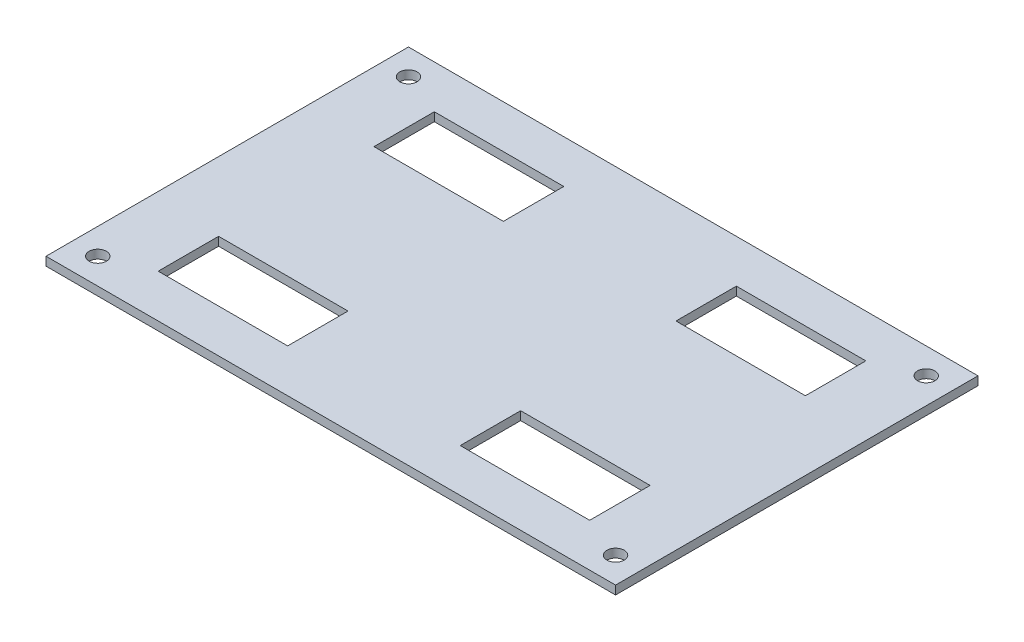
from build123d import *

# Parameters (mm, degrees)
SKETCH1_W           = 66
SKETCH1_H           = 42
SKETCH1_R           = 1
SKETCH1_W_2         = 15
SKETCH1_H_2         = 7
BOSS_EXTRUDE1_DEPTH = 1


with BuildPart() as part:
    # Sketch1 → Boss-Extrude1 (new body)
    with BuildSketch(Plane(origin=(0, 0, 0), x_dir=(1, 0, 0), z_dir=(0, 1, 0))):
        Rectangle(SKETCH1_W, SKETCH1_H)
        with Locations((-30, -18)):
            Circle(SKETCH1_R, mode=Mode.SUBTRACT)
        with Locations((30, -18)):
            Circle(SKETCH1_R, mode=Mode.SUBTRACT)
        with Locations((30, 18)):
            Circle(SKETCH1_R, mode=Mode.SUBTRACT)
        with Locations((-30, 18)):
            Circle(SKETCH1_R, mode=Mode.SUBTRACT)
        with Locations((-17.5, -12.5)):
            Rectangle(SKETCH1_W_2, SKETCH1_H_2, mode=Mode.SUBTRACT)
        with Locations((17.5, -12.5)):
            Rectangle(SKETCH1_W_2, SKETCH1_H_2, mode=Mode.SUBTRACT)
        with Locations((17.5, 12.5)):
            Rectangle(SKETCH1_W_2, SKETCH1_H_2, mode=Mode.SUBTRACT)
        with Locations((-17.5, 12.5)):
            Rectangle(SKETCH1_W_2, SKETCH1_H_2, mode=Mode.SUBTRACT)
    extrude(amount=BOSS_EXTRUDE1_DEPTH)


solid = part.part
